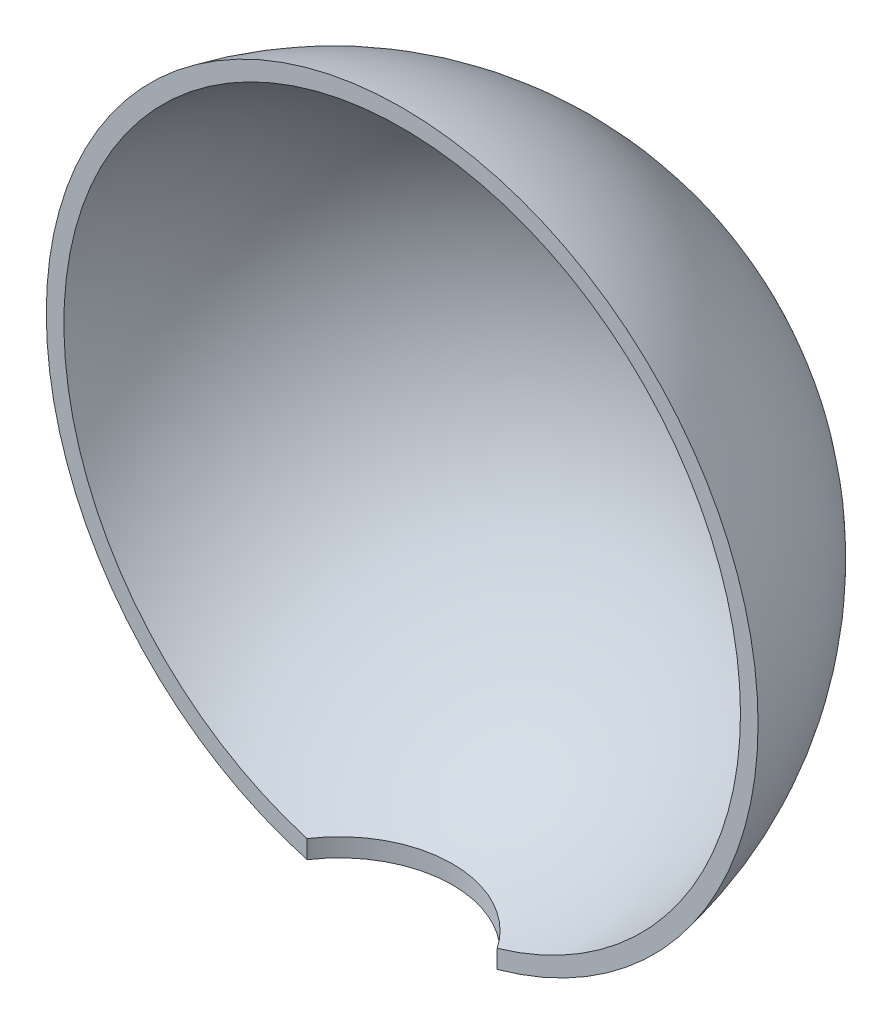
from build123d import *

# Parameters (mm, degrees)
SHELL1_T                = 1.5
CUT_EXTRUDE1_REACH      = 55.684
CUT_EXTRUDE1_END_RADIUS = 31.5
SKETCH3_R               = 10


with BuildPart() as part:
    # Sketch2 → Revolve1 (revolve)
    with BuildSketch(Plane(origin=(0, 0, 0), x_dir=(1, 0, 0), z_dir=(0, 1, 0))):
        with BuildLine():
            Line((0, 29.63583815), (0, 5.63583815))
            Line((0, 5.63583815), (29.393876913, 5.63583815))
            ThreePointArc((29.393876913, 5.63583815), (18.973665961, 22.873738228), (0, 29.63583815))
        make_face()
    revolve(axis=Axis((0, 0, -29.63583815), (0, 0, 1)))

    # Shell1
    shell1_openings = [part.faces().sort_by_distance(p)[0] for p in [
        (0, 0, -5.63583815),
    ]]
    offset(amount=SHELL1_T, openings=shell1_openings, kind=Kind.INTERSECTION)

    # Cut-Extrude1: up to this sphere (the profile starts inside it)
    cut_extrude1_end = Location((0, 0, 0.36416185)) * Sphere(CUT_EXTRUDE1_END_RADIUS, mode=Mode.PRIVATE)
    # Sketch3 → Cut-Extrude1 (cut, up to the surface)
    with BuildSketch(Plane(origin=(0, 0, 0), x_dir=(1, 0, 0), z_dir=(0, 1, 0)), mode=Mode.PRIVATE) as cut_extrude1_sk1:
        Circle(SKETCH3_R)
    cut_extrude1_tool1 = extrude(cut_extrude1_sk1.sketch, amount=-CUT_EXTRUDE1_REACH, mode=Mode.PRIVATE) & cut_extrude1_end
    add(cut_extrude1_tool1.solids().sort_by_distance((0, 0, 0))[0], mode=Mode.SUBTRACT)


solid = part.part
